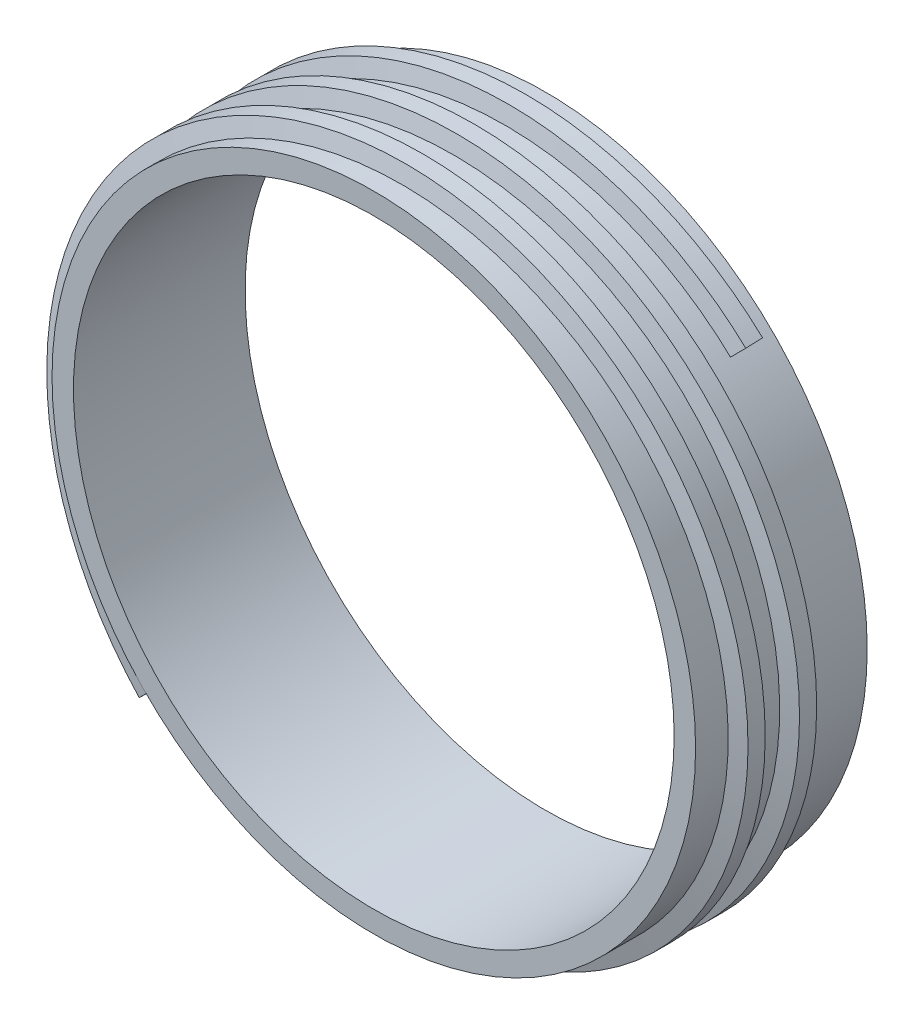
from build123d import *

# Parameters (mm, degrees)
SKETCH_1_R          = 37.5
SKETCH_1_R_2        = 35
EXTRUDE_1_DEPTH     = 20
SWEEP_1_PITCH       = 6
SWEEP_1_HEIGHT      = 15
SWEEP_1_RADIUS      = 37.35
SWEEP_1_START_ANGLE = -45


with BuildPart() as part:
    # 草图1 → 凸台-拉伸1 (new body)
    with BuildSketch(Plane.XY):
        Circle(SKETCH_1_R)
        Circle(SKETCH_1_R_2, mode=Mode.SUBTRACT)
    extrude(amount=EXTRUDE_1_DEPTH)


with BuildPart() as body_2:
    # 扫描1: sweep along a helix
    with BuildLine() as sweep_1_path:
        add(Helix(SWEEP_1_PITCH, SWEEP_1_HEIGHT, SWEEP_1_RADIUS, center=(0, 0, 18.5), direction=(0, 0, -1), mode=Mode.PRIVATE).rotate(Axis((0, 0, 18.5), (0, 0, -1)), SWEEP_1_START_ANGLE))
    # 草图6 → 扫描1 (sweep)
    with BuildSketch(Plane(origin=(-26.410438277, -26.410438277, 18.5), x_dir=(-0.018072735, 0.018072735, 0.999673323), z_dir=(-0.706875786, 0.706875786, -0.025558707))):
        Polygon((1.5, 0), (-1.5, 0), (-1, -2), (1, -2), align=None)
    sweep(path=sweep_1_path.line, is_frenet=True)


solid = Compound([part.part, body_2.part])
